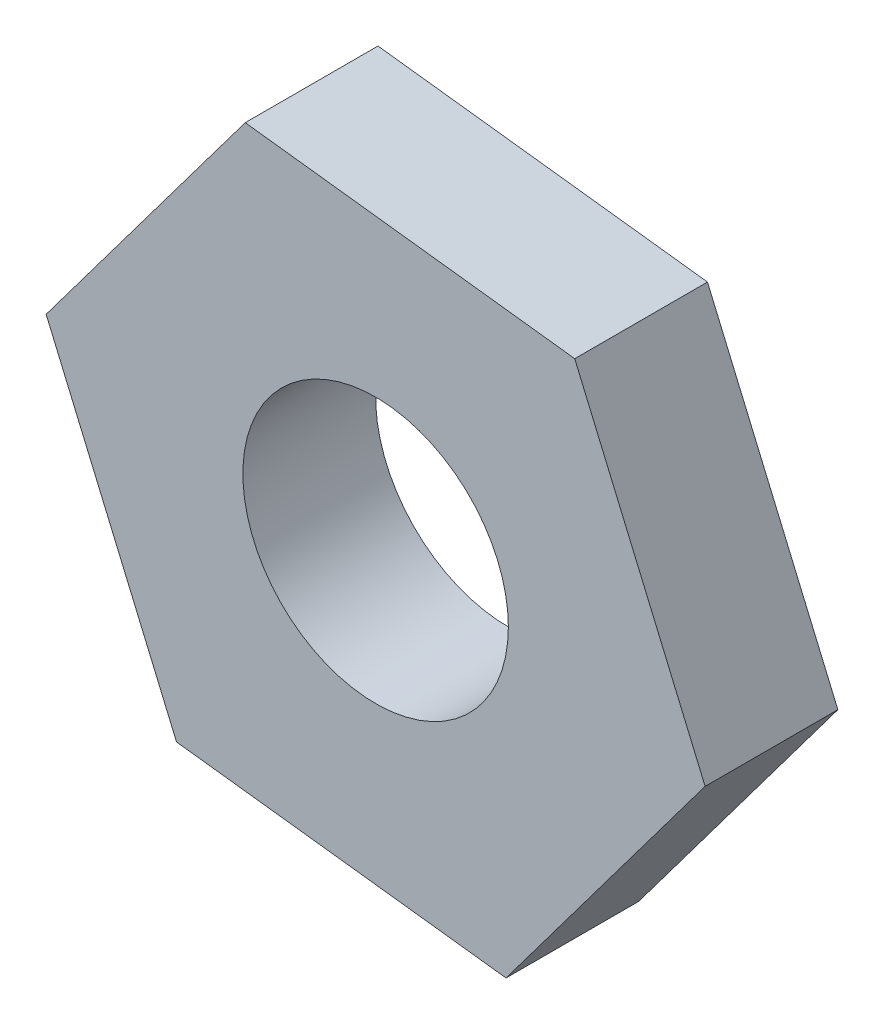
from build123d import *

# Parameters (mm, degrees)
BOSS_EXTRUDE1_DEPTH = 4
SKETCH2_R           = 4
CUT_EXTRUDE1_DEPTH  = 4


with BuildPart() as part:
    # Sketch1 → Boss-Extrude1 (new body)
    with BuildSketch(Plane.XY):
        Polygon((2.730304444, 2.302220599), (-1.198694049, 11.498033279), (-11.127000685, 12.693327112), (-17.126308828, 4.692808266), (-13.197310334, -4.503004414), (-3.269003699, -5.698298248), align=None)
    extrude(amount=BOSS_EXTRUDE1_DEPTH)

    # Sketch2 → Cut-Extrude1 (cut)
    with BuildSketch(Plane.XY.offset(4)):
        with Locations((-7.198002192, 3.497514432)):
            Circle(SKETCH2_R)
    extrude(amount=-CUT_EXTRUDE1_DEPTH, mode=Mode.SUBTRACT)


solid = part.part
